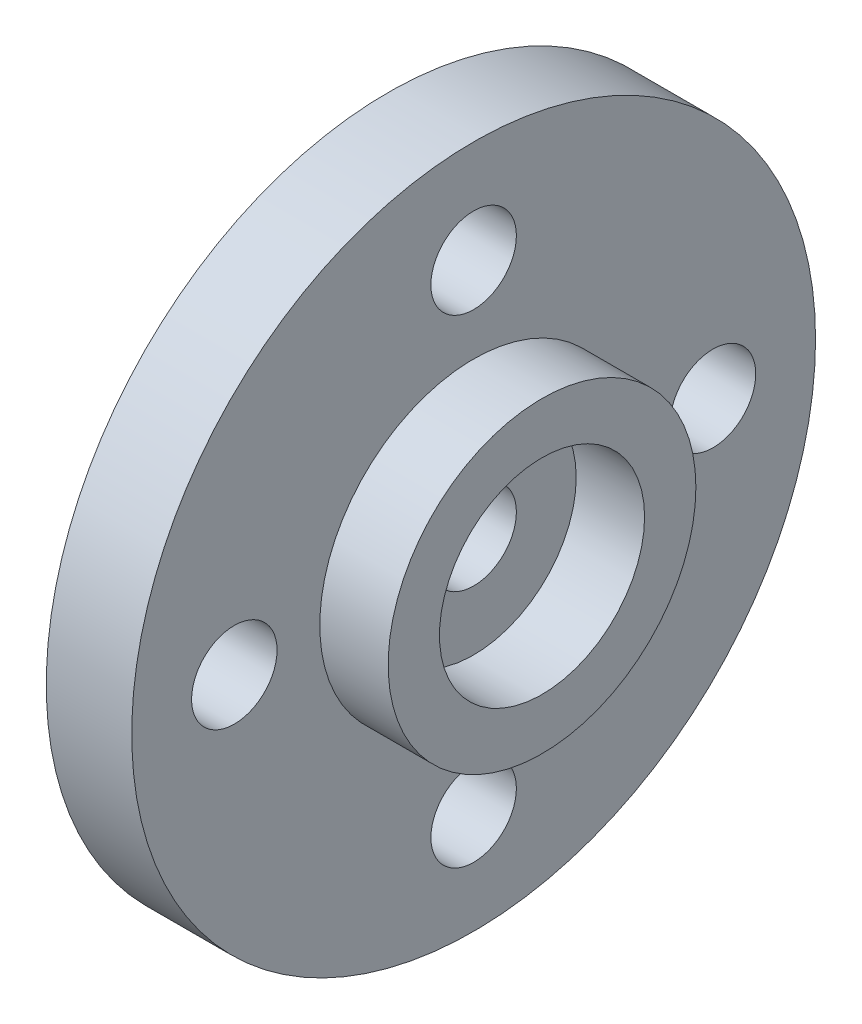
from build123d import *

# Parameters (mm, degrees)
SKETCH_1_R         = 10
EXTRUDE_1_DEPTH    = 2.5
SKETCH_2_R         = 4.5
SKETCH_2_R_2       = 3
EXTRUDE_2_DEPTH    = 2
HOLE_WIZARD_M3_1_D = 2.5


with BuildPart() as part:
    # 草图1 → 凸台-拉伸1 (new body)
    with BuildSketch(Plane(origin=(0, 0, 0), x_dir=(0, 0, -1), z_dir=(1, 0, 0))):
        Circle(SKETCH_1_R)
    extrude(amount=EXTRUDE_1_DEPTH)

    # 草图2 → 凸台-拉伸2 (add)
    with BuildSketch(Plane(origin=(2.5, 0, 0), x_dir=(0, 0, -1), z_dir=(1, 0, 0))):
        Circle(SKETCH_2_R)
        Circle(SKETCH_2_R_2, mode=Mode.SUBTRACT)
    extrude(amount=EXTRUDE_2_DEPTH)

    # M3 螺纹孔1 (through all)
    with Locations(Plane.ZY):
        with Locations((0, 0), (0, 7), (-7, 0), (7, 0), (0, -7)):
            Hole(HOLE_WIZARD_M3_1_D / 2)


solid = part.part
